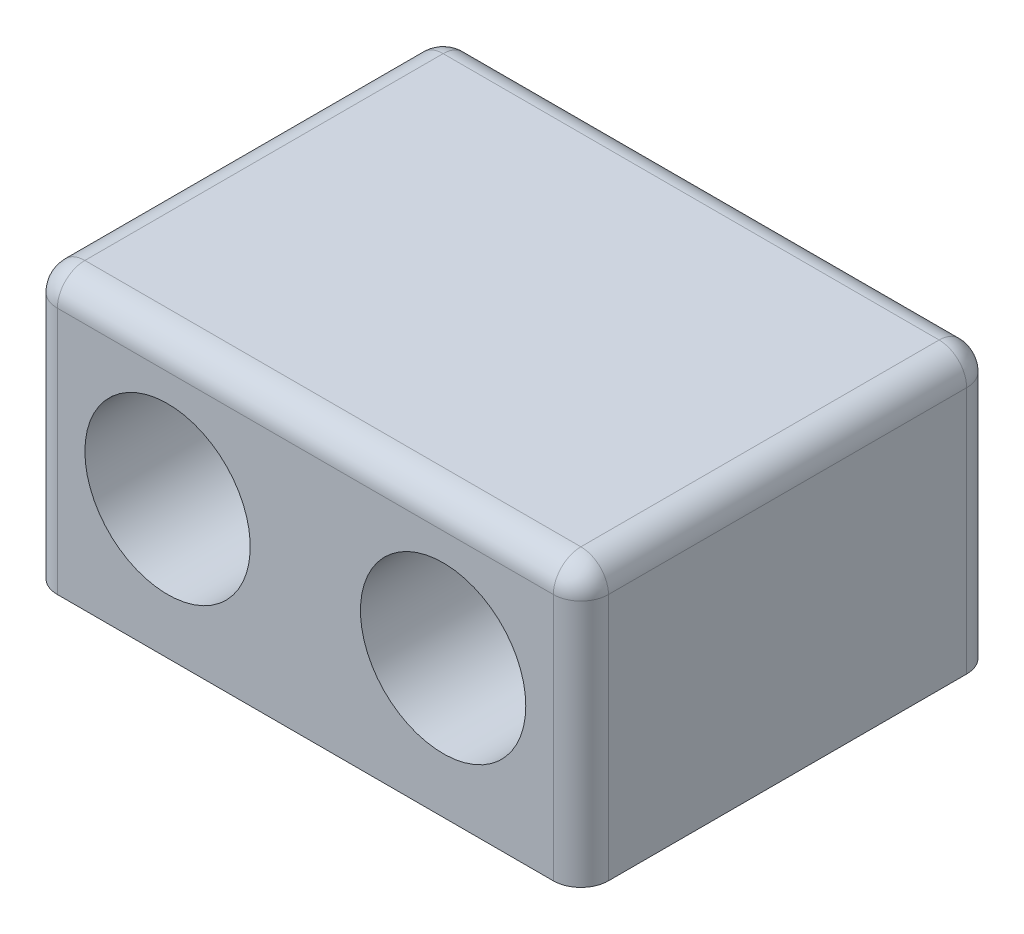
from build123d import *

# Parameters (mm, degrees)
SKETCH1_W           = 20
SKETCH1_H           = 15
BOSS_EXTRUDE1_DEPTH = 10
SKETCH4_R           = 3
CUT_EXTRUDE1_DEPTH  = 8
CUT_EXTRUDE2_DEPTH  = 8
FILLET1_R           = 1


with BuildPart() as part:
    # Sketch1 → Boss-Extrude1 (new body)
    with BuildSketch(Plane(origin=(0, 0, 0), x_dir=(1, 0, 0), z_dir=(0, 1, 0))):
        Rectangle(SKETCH1_W, SKETCH1_H)
    extrude(amount=BOSS_EXTRUDE1_DEPTH)

    # Sketch4 → Cut-Extrude1 (cut)
    with BuildSketch(Plane.XY.offset(7.5)):
        with Locations((5, 5)):
            Circle(SKETCH4_R)
    cut_extrude1 = extrude(amount=-CUT_EXTRUDE1_DEPTH, mode=Mode.SUBTRACT)

    # Sketch6 → Cut-Extrude2 (cut, through all)
    with BuildSketch(Plane.XY.offset(-0.5)):
        with BuildLine():
            Line((3.75, 5.75), (6.25, 5.75))
            ThreePointArc((6.25, 5.75), (7, 5), (6.25, 4.25))
            Line((6.25, 4.25), (3.75, 4.25))
            ThreePointArc((3.75, 4.25), (3, 5), (3.75, 5.75))
        make_face()
    cut_extrude2 = extrude(amount=-CUT_EXTRUDE2_DEPTH, mode=Mode.SUBTRACT)

    # Mirror1: Cut-Extrude1, Cut-Extrude2 across plane
    add(cut_extrude1.mirror(Plane(origin=(0, 0, 0), x_dir=(0, 0, 1), z_dir=(1, 0, 0))), mode=Mode.SUBTRACT)
    add(cut_extrude2.mirror(Plane(origin=(0, 0, 0), x_dir=(0, 0, 1), z_dir=(1, 0, 0))), mode=Mode.SUBTRACT)

    # Fillet1
    fillet1_edges = [part.edges().sort_by_distance(p)[0] for p in [
        (-10, 10, 0),
        (0, 10, 7.5),
        (10, 10, 0),
        (0, 10, -7.5),
        (10, 5, 7.5),
        (-10, 5, 7.5),
        (-10, 5, -7.5),
        (10, 5, -7.5),
    ]]
    fillet(fillet1_edges, radius=FILLET1_R)


solid = part.part
